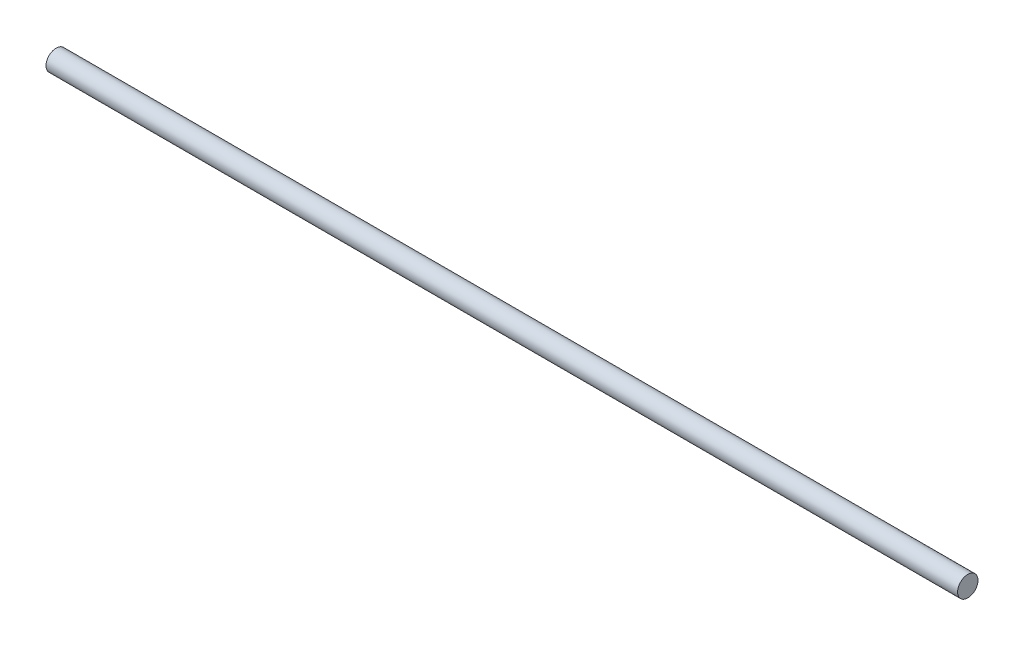
from build123d import *

# Parameters (mm, degrees)
SKETCH1_W = 134
SKETCH1_H = 1.5


with BuildPart() as part:
    # Sketch1 → Revolve1 (revolve)
    with BuildSketch(Plane.XY):
        with Locations((67, -0.75)):
            Rectangle(SKETCH1_W, SKETCH1_H)
    revolve(axis=Axis((0, 0, 0), (1, 0, 0)))


solid = part.part
